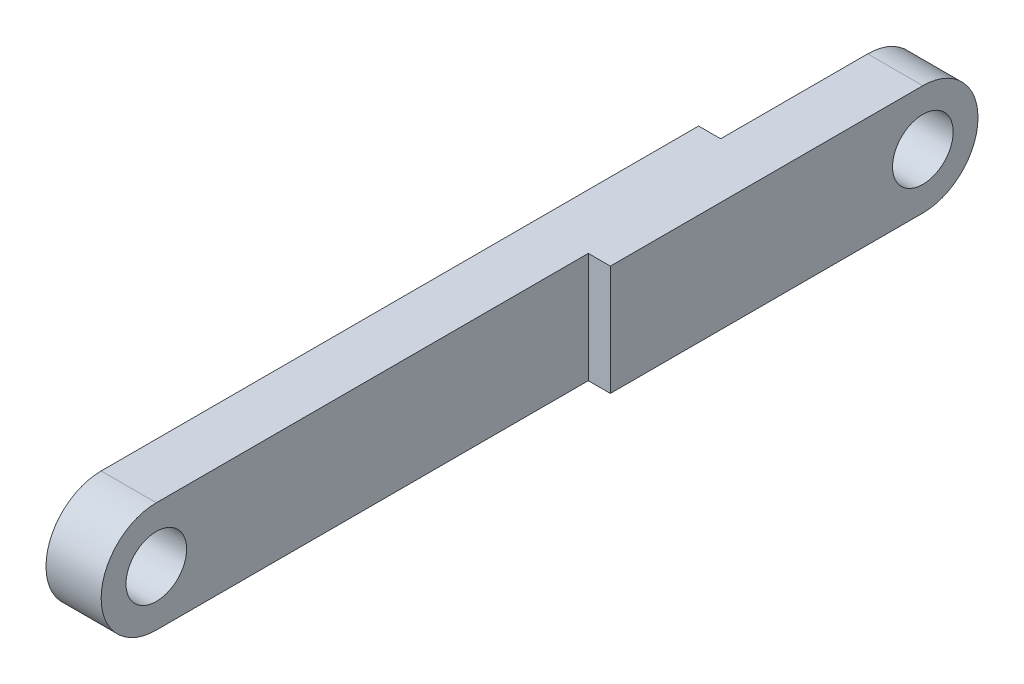
from build123d import *

# Parameters (mm, degrees)
SKETCH1_R           = 1.65
BOSS_EXTRUDE1_DEPTH = 3
SKETCH3_W           = 11
SKETCH3_H           = 6
CUT_EXTRUDE2_DEPTH  = 1.2
SKETCH4_R           = 1.65
BOSS_EXTRUDE2_DEPTH = 1.2


with BuildPart() as part:
    # Sketch1 → Boss-Extrude1 (new body)
    with BuildSketch(Plane(origin=(0, 0, 0), x_dir=(0, 0, -1), z_dir=(1, 0, 0))):
        with BuildLine():
            Line((0, 3), (40.5, 3))
            ThreePointArc((40.5, 3), (43.5, 0), (40.5, -3))
            Line((40.5, -3), (0, -3))
            ThreePointArc((0, -3), (-3, 0), (0, 3))
        make_face()
        Circle(SKETCH1_R, mode=Mode.SUBTRACT)
        with Locations((40.5, 0)):
            Circle(SKETCH1_R, mode=Mode.SUBTRACT)
    extrude(amount=BOSS_EXTRUDE1_DEPTH)

    # Sketch3 → Cut-Extrude2 (cut)
    with BuildSketch(Plane.ZY):
        with Locations((-38, 0)):
            Rectangle(SKETCH3_W, SKETCH3_H)
    extrude(amount=-CUT_EXTRUDE2_DEPTH, mode=Mode.SUBTRACT)

    # Sketch4 → Boss-Extrude2 (add)
    with BuildSketch(Plane(origin=(3, 0, 0), x_dir=(0, 0, -1), z_dir=(1, 0, 0))):
        with BuildLine():
            Line((40.5, 3), (23.5, 3))
            Line((23.5, 3), (23.5, -3))
            Line((23.5, -3), (40.5, -3))
            ThreePointArc((40.5, -3), (43.5, 0), (40.5, 3))
        make_face()
        with Locations((40.5, 0)):
            Circle(SKETCH4_R, mode=Mode.SUBTRACT)
    extrude(amount=BOSS_EXTRUDE2_DEPTH)


solid = part.part
